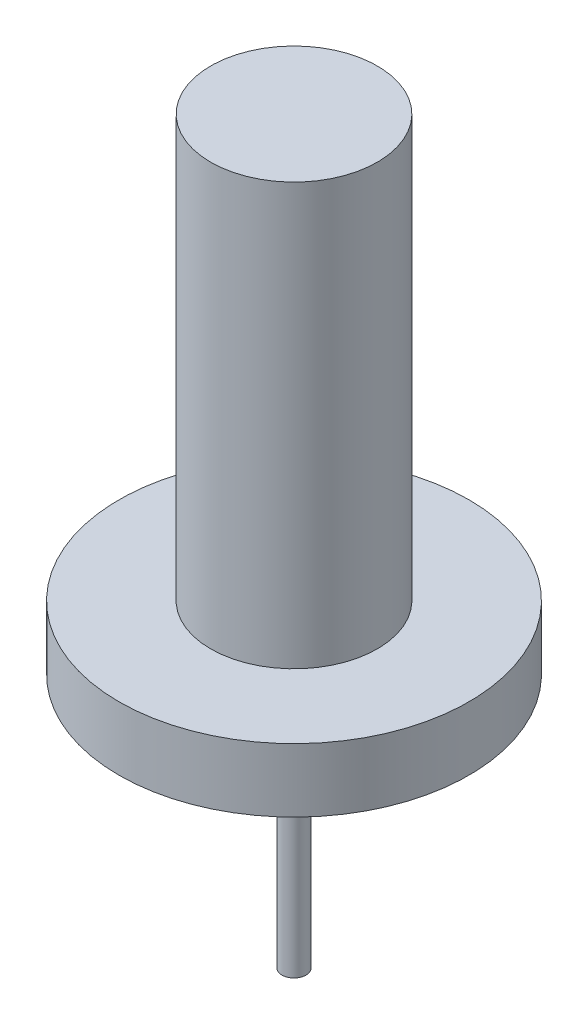
from build123d import *

# Parameters (mm, degrees)
SKETCH1_R      = 34.925
EXTRUDE1_DEPTH = 12.7
SKETCH2_R      = 16.637
EXTRUDE2_DEPTH = 84.1248
SKETCH3_R      = 2.40792343
EXTRUDE3_DEPTH = 50.8


with BuildPart() as part:
    # Sketch1 → Extrude1 (new body)
    with BuildSketch(Plane(origin=(0, 0, 0), x_dir=(1, 0, 0), z_dir=(0, 1, 0))):
        Circle(SKETCH1_R)
    extrude(amount=EXTRUDE1_DEPTH)

    # Sketch2 → Extrude2 (add)
    with BuildSketch(Plane(origin=(0, 12.7, 0), x_dir=(1, 0, 0), z_dir=(0, 1, 0))):
        Circle(SKETCH2_R)
    extrude(amount=EXTRUDE2_DEPTH)

    # Sketch3 → Extrude3 (add)
    with BuildSketch(Plane.XZ):
        Circle(SKETCH3_R)
    extrude(amount=EXTRUDE3_DEPTH)


solid = part.part
